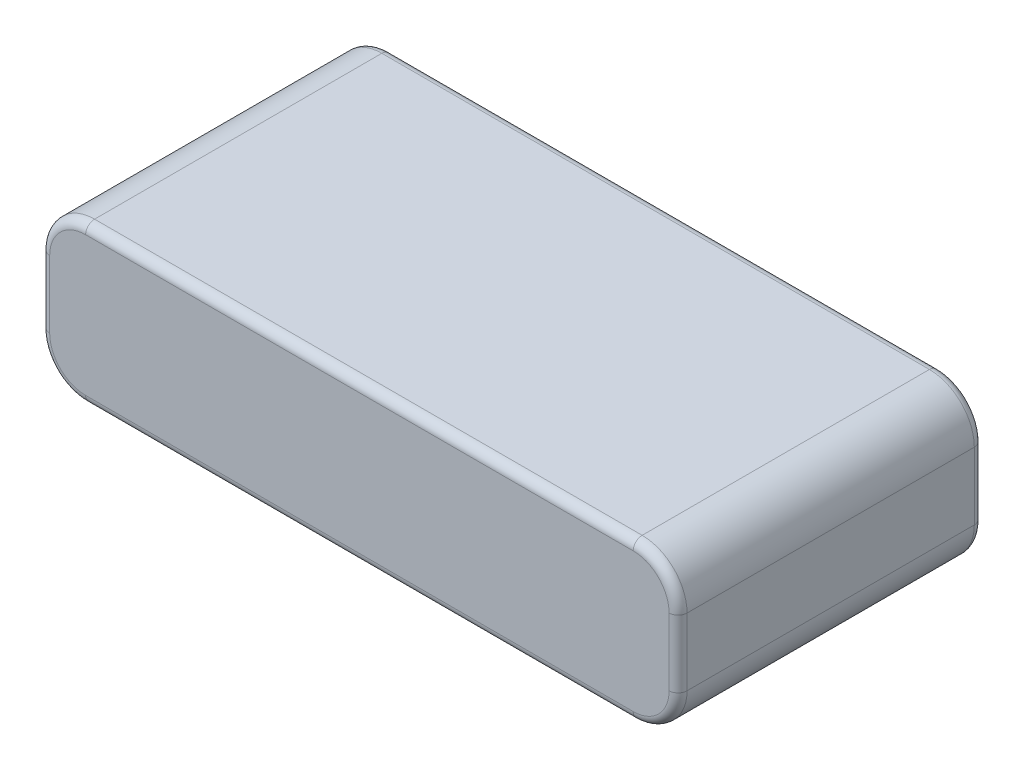
from build123d import *

# Parameters (mm, degrees)
SKETCH1_W           = 71
SKETCH1_H           = 34
BOSS_EXTRUDE1_DEPTH = 17.5
FILLET1_R           = 5
FILLET2_R           = 1
SKETCH4_W           = 0.987179487
SKETCH4_H           = 5.5
SKETCH4_W_2         = 1.903846154
SKETCH4_H_2         = 0.916666667
BOSS_EXTRUDE3_DEPTH = 0.5


with BuildPart() as part:
    # Sketch1 → Boss-Extrude1 (new body)
    with BuildSketch(Plane(origin=(0, 0, 0), x_dir=(1, 0, 0), z_dir=(0, 1, 0))):
        Rectangle(SKETCH1_W, SKETCH1_H)
    extrude(amount=BOSS_EXTRUDE1_DEPTH)

    # Fillet1
    fillet1_edges = [part.edges().sort_by_distance(p)[0] for p in [
        (-35.5, 17.5, 0),
        (35.5, 17.5, 0),
        (-35.5, 0, 0),
        (35.5, 0, 0),
    ]]
    fillet(fillet1_edges, radius=FILLET1_R)

    # Fillet2
    fillet2_edges = [part.edges().sort_by_distance(p)[0] for p in [
        (35.5, 8.75, -17),
        (35.5, 8.75, 17),
        (0, 0, -17),
        (-35.5, 8.75, -17),
        (0, 17.5, -17),
        (-34.035533906, 1.464466094, -17),
        (-34.035533906, 16.035533906, -17),
        (34.035533906, 16.035533906, -17),
        (34.035533906, 1.464466094, -17),
        (0, 0, 17),
        (0, 17.5, 17),
        (-35.5, 8.75, 17),
        (-34.035533906, 1.464466094, 17),
        (-34.035533906, 16.035533906, 17),
        (34.035533906, 16.035533906, 17),
        (34.035533906, 1.464466094, 17),
    ]]
    fillet(fillet2_edges, radius=FILLET2_R)

    # Sketch4 → Boss-Extrude3 (add)
    with BuildSketch(Plane.XZ):
        Polygon((-15.393881642, 2.960580474), (-14.478316738, 2.960580474), (-12.257162892, -2.539419526), (-13.311549911, -2.539419526), (-13.739033886, -1.411214398), (-16.13536802, -1.411214398), (-16.562851995, -2.539419526), (-17.616137251, -2.539419526), align=None)
        Polygon((-14.936650071, 1.485320057), (-15.760768661, -0.424034911), (-14.112531482, -0.424034911), align=None, mode=Mode.SUBTRACT)
        with BuildLine():
            Line((-11.446265456, 2.960580474), (-10.296025071, 2.960580474))
            add(Edge.make_bspline(
                [(-10.296025071, 2.960580474), (-10.219994532, 2.960310609), (-10.073766388, 2.959791583), (-9.862913392, 2.951602728), (-9.669215918, 2.940207263), (-9.492387179, 2.922817483), (-9.332502826, 2.899760735), (-9.189402618, 2.872580645), (-9.063090736, 2.841603106), (-8.952501915, 2.803002648), (-8.852700973, 2.759461916), (-8.75967262, 2.709432817), (-8.671364512, 2.65347244), (-8.588366894, 2.590108317), (-8.509958496, 2.520480352), (-8.435991397, 2.444518458), (-8.367510821, 2.361578509), (-8.304940801, 2.272184582), (-8.247913264, 2.17814422), (-8.197512883, 2.079328305), (-8.156527209, 1.975668119), (-8.120311972, 1.868661773), (-8.094227311, 1.756779593), (-8.07608581, 1.64111077), (-8.062803313, 1.521248137), (-8.062039633, 1.439818785), (-8.061650071, 1.398280794)],
                knots=[0, 0, 0, 0, 0.000228076, 0.000438654, 0.000632942, 0.000810103, 0.000971526, 0.001117379, 0.001246981, 0.001361267, 0.001468325, 0.001573317, 0.001677845, 0.001781633, 0.001886214, 0.001992178, 0.002099389, 0.002208514, 0.002319239, 0.002429118, 0.002540826, 0.002653362, 0.002767739, 0.00288493, 0.003004536, 0.003129079, 0.003129079, 0.003129079, 0.003129079], degree=3))
            add(Edge.make_bspline(
                [(-8.061650071, 1.398280794), (-8.062662012, 1.354924674), (-8.064646243, 1.269911223), (-8.075334391, 1.145033398), (-8.094868967, 1.02555903), (-8.124456925, 0.911837924), (-8.15846444, 0.802454691), (-8.203685711, 0.699427517), (-8.254722385, 0.601258023), (-8.315337151, 0.509334854), (-8.381858896, 0.421616211), (-8.459222286, 0.341462922), (-8.542415362, 0.26456705), (-8.636114709, 0.195745093), (-8.736189974, 0.130343558), (-8.844629546, 0.07107235), (-8.960725712, 0.016441528), (-9.042347066, -0.014024392), (-9.084085969, -0.029603821)],
                knots=[0, 0, 0, 0, 0.000130083, 0.000255068, 0.0003757, 0.000492741, 0.000607372, 0.000718912, 0.000829802, 0.000938899, 0.001048866, 0.001159537, 0.001272632, 0.001388317, 0.001507807, 0.001631086, 0.001758748, 0.001892352, 0.001892352, 0.001892352, 0.001892352], degree=3))
            Line((-9.084085969, -0.029603821), (-7.8148552, -2.539419526))
            Line((-7.8148552, -2.539419526), (-8.912210969, -2.539419526))
            Line((-8.912210969, -2.539419526), (-10.124150071, -0.141983629))
            Line((-10.124150071, -0.141983629), (-10.459085969, -0.141983629))
            Line((-10.459085969, -0.141983629), (-10.459085969, -2.539419526))
            Line((-10.459085969, -2.539419526), (-11.446265456, -2.539419526))
            Line((-11.446265456, -2.539419526), (-11.446265456, 2.960580474))
        make_face()
        with BuildLine():
            Line((-10.459085969, 0.845195858), (-10.074570745, 0.845195858))
            add(Edge.make_bspline(
                [(-10.074570745, 0.845195858), (-10.027560562, 0.845725319), (-9.937546164, 0.846739121), (-9.808093637, 0.851441558), (-9.690519869, 0.862772107), (-9.58431996, 0.877087833), (-9.488959521, 0.893617406), (-9.405289133, 0.917305287), (-9.332019564, 0.942687451), (-9.27001906, 0.974230897), (-9.217047255, 1.010102637), (-9.171309491, 1.050853825), (-9.133477802, 1.098018136), (-9.102340393, 1.150313848), (-9.078118873, 1.208203503), (-9.06043902, 1.271051604), (-9.050558596, 1.339574072), (-9.04942182, 1.386863905), (-9.048829559, 1.411501948)],
                knots=[0, 0, 0, 0, 0.000141043, 0.000270067, 0.000388469, 0.000495204, 0.000591581, 0.000678453, 0.000755828, 0.000823825, 0.000886471, 0.000947318, 0.001006854, 0.001067129, 0.001129338, 0.001194565, 0.0012625, 0.001336392, 0.001336392, 0.001336392, 0.001336392], degree=3))
            add(Edge.make_bspline(
                [(-9.048829559, 1.411501948), (-9.049949283, 1.440650551), (-9.052148775, 1.497907581), (-9.073974562, 1.580337626), (-9.108716501, 1.656632273), (-9.156338184, 1.726446804), (-9.216311502, 1.78765104), (-9.285135617, 1.841603062), (-9.364295918, 1.884264284), (-9.4375924, 1.912403172), (-9.504275066, 1.929238959), (-9.564454069, 1.941784838), (-9.634141716, 1.950676463), (-9.713390618, 1.960107614), (-9.801998768, 1.966223238), (-9.900449131, 1.970686425), (-10.00845896, 1.972512534), (-10.083752069, 1.973096308), (-10.123048309, 1.973400986)],
                knots=[0, 0, 0, 0, 8.729e-05, 0.000171465, 0.000253803, 0.000337841, 0.000423552, 0.00050994, 0.00059919, 0.000692294, 0.000744671, 0.000805388, 0.000876594, 0.000955315, 0.001044802, 0.001142958, 0.001250953, 0.001368847, 0.001368847, 0.001368847, 0.001368847], degree=3))
            Line((-10.123048309, 1.973400986), (-10.459085969, 1.973400986))
            Line((-10.459085969, 1.973400986), (-10.459085969, 0.845195858))
        make_face(mode=Mode.SUBTRACT)
        with Locations((-6.651393662, 0.210580474)):
            Rectangle(SKETCH4_W, SKETCH4_H)
        Polygon((-4.888573148, 2.960580474), (-2.209085969, 2.960580474), (-2.209085969, 1.973400986), (-3.901393661, 1.973400986), (-3.901393661, 0.915708679), (-2.209085969, 0.915708679), (-2.209085969, -0.071470808), (-3.901393661, -0.071470808), (-3.901393661, -2.539419526), (-4.888573148, -2.539419526), align=None)
        with BuildLine():
            Line((-1.221906482, 2.960580474), (-0.234726995, 2.960580474))
            Line((-0.234726995, 2.960580474), (-0.234726995, -0.617945167))
            add(Edge.make_bspline(
                [(-0.234726995, -0.617945167), (-0.234673317, -0.655045769), (-0.234569638, -0.726705198), (-0.229379443, -0.829513017), (-0.224630056, -0.924014928), (-0.216060815, -1.010107472), (-0.203401109, -1.087827477), (-0.191142382, -1.157674187), (-0.174551407, -1.218397077), (-0.149617825, -1.287515624), (-0.111203359, -1.365174086), (-0.048436254, -1.446111517), (0.023991616, -1.519978671), (0.110800589, -1.58146289), (0.208366198, -1.631198082), (0.316152364, -1.668046356), (0.434007144, -1.688529103), (0.515497261, -1.691656169), (0.557440473, -1.69326568)],
                knots=[0, 0, 0, 0, 0.000111283, 0.000214943, 0.000308755, 0.000395143, 0.000474301, 0.00054496, 0.000607771, 0.000662837, 0.000765324, 0.000866026, 0.000968862, 0.001074654, 0.001183551, 0.001296437, 0.001415085, 0.001540923, 0.001540923, 0.001540923, 0.001540923], degree=3))
            add(Edge.make_bspline(
                [(0.557440473, -1.69326568), (0.601999961, -1.691965402), (0.688883418, -1.68943008), (0.813851439, -1.664543149), (0.929635019, -1.624914631), (1.033782625, -1.568354637), (1.126190613, -1.500557572), (1.204412039, -1.423247672), (1.266144101, -1.336270743), (1.306378762, -1.256027903), (1.328968543, -1.182171356), (1.345900709, -1.116183333), (1.35831386, -1.038323999), (1.369575479, -0.949809294), (1.376342844, -0.849722377), (1.383680948, -0.738868158), (1.386370432, -0.616488145), (1.386828834, -0.531272645), (1.387067877, -0.486835392)],
                knots=[0, 0, 0, 0, 0.000133536, 0.000260373, 0.000380586, 0.000499383, 0.00061441, 0.000723479, 0.000827734, 0.000933181, 0.000991021, 0.001059162, 0.00113741, 0.00122733, 0.001326789, 0.001438263, 0.001560603, 0.001693921, 0.001693921, 0.001693921, 0.001693921], degree=3))
            Line((1.387067877, -0.486835392), (1.387067877, 2.960580474))
            Line((1.387067877, 2.960580474), (2.374247364, 2.960580474))
            Line((2.374247364, 2.960580474), (2.374247364, -0.320469206))
            add(Edge.make_bspline(
                [(2.374247364, -0.320469206), (2.374110277, -0.386943115), (2.37384667, -0.514765961), (2.369798469, -0.698456385), (2.361180581, -0.866228122), (2.353942549, -1.018130194), (2.339934479, -1.153957965), (2.325341356, -1.274291458), (2.306741166, -1.378704238), (2.2790652, -1.497565498), (2.231304678, -1.634429887), (2.154308453, -1.792023298), (2.05656673, -1.946316792), (1.941040898, -2.095613037), (1.810601666, -2.234304436), (1.668141152, -2.356057533), (1.515922697, -2.459047524), (1.35235573, -2.54075618), (1.177579454, -2.604482771), (0.989864587, -2.647303831), (0.789339137, -2.676234276), (0.650832419, -2.679013402), (0.57947573, -2.680445167)],
                knots=[0, 0, 0, 0, 0.000199422, 0.000383469, 0.000551115, 0.000703413, 0.000839573, 0.000960652, 0.001066982, 0.001157575, 0.001326562, 0.001500504, 0.001682692, 0.001873539, 0.002066045, 0.002252829, 0.002434646, 0.002615969, 0.002799993, 0.002991336, 0.003192648, 0.003406571, 0.003406571, 0.003406571, 0.003406571], degree=3))
            add(Edge.make_bspline(
                [(0.57947573, -2.680445167), (0.532064926, -2.679646595), (0.438524383, -2.678071028), (0.300956605, -2.664178644), (0.167970324, -2.643706492), (0.03981542, -2.613839732), (-0.083952908, -2.575257456), (-0.203301779, -2.527765362), (-0.317787662, -2.471628353), (-0.426769911, -2.40736277), (-0.530114414, -2.337870604), (-0.624565956, -2.260835614), (-0.713374834, -2.181954826), (-0.793975399, -2.097908604), (-0.866973032, -2.009579288), (-0.932217394, -1.916766696), (-0.989611554, -1.819479072), (-1.04059923, -1.715962811), (-1.084239704, -1.600956557), (-1.121030264, -1.470369489), (-1.153171362, -1.322154785), (-1.17705673, -1.155978526), (-1.198711345, -0.97238841), (-1.212417522, -0.770906156), (-1.219587841, -0.551525985), (-1.221114072, -0.39943426), (-1.221906482, -0.320469206)],
                knots=[0, 0, 0, 0, 0.000142196, 0.000280549, 0.000414408, 0.000545629, 0.000674911, 0.000802986, 0.000930605, 0.00105702, 0.001182311, 0.00130379, 0.001422372, 0.001538476, 0.001652741, 0.001765837, 0.001878454, 0.001991292, 0.002111606, 0.002246904, 0.002397958, 0.002566243, 0.002750329, 0.00295246, 0.003171846, 0.003408749, 0.003408749, 0.003408749, 0.003408749], degree=3))
            Line((-1.221906482, -0.320469206), (-1.221906482, 2.960580474))
        make_face()
        Polygon((3.643478134, 2.960580474), (4.630657621, 2.960580474), (4.630657621, -1.552240039), (6.181939672, -1.552240039), (6.181939672, -2.539419526), (3.643478134, -2.539419526), align=None)
        with Locations((7.980016595, -0.529804141)):
            Rectangle(SKETCH4_W_2, SKETCH4_H_2)
        Polygon((11.992636788, 3.101606115), (13.021683262, 3.101606115), (13.021683262, -0.494547731), (13.515273005, -0.494547731), (13.515273005, -1.411214398), (13.021683262, -1.411214398), (13.021683262, -2.539419526), (12.034503775, -2.539419526), (12.034503775, -1.411214398), (9.707580698, -1.411214398), (9.707580698, -0.41191552), align=None)
        Polygon((12.034503775, -0.494547731), (12.034503775, 1.377347301), (10.817055858, -0.494547731), align=None, mode=Mode.SUBTRACT)
        Polygon((16.223406018, 3.101606115), (17.252452493, 3.101606115), (17.252452493, -0.494547731), (17.746042236, -0.494547731), (17.746042236, -1.411214398), (17.252452493, -1.411214398), (17.252452493, -2.539419526), (16.265273005, -2.539419526), (16.265273005, -1.411214398), (13.938349929, -1.411214398), (13.938349929, -0.41191552), align=None)
        Polygon((16.265273005, -0.494547731), (16.265273005, 1.377347301), (15.047825089, -0.494547731), align=None, mode=Mode.SUBTRACT)
    extrude(amount=BOSS_EXTRUDE3_DEPTH)


solid = part.part
